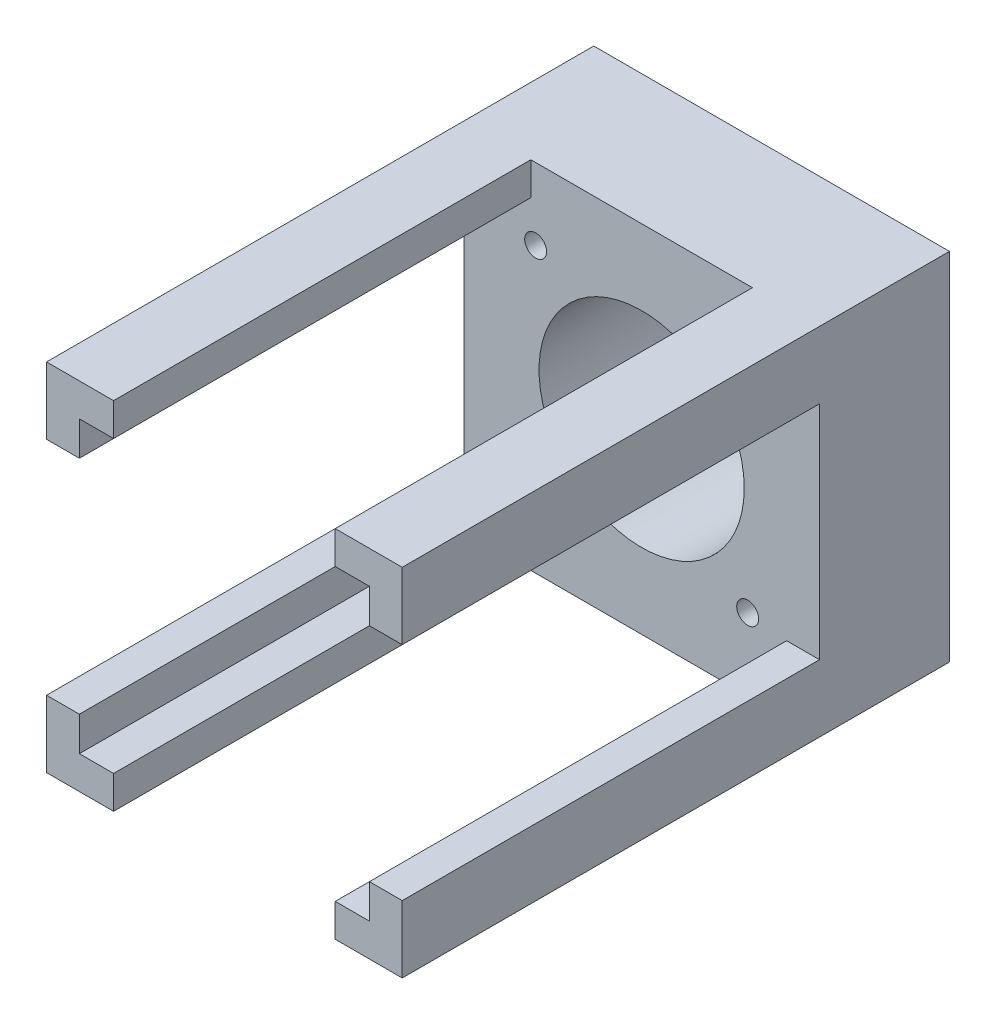
from build123d import *

# Parameters (mm, degrees)
SKETCH_1_W          = 52
SKETCH_1_H          = 52
SKETCH_1_R          = 15
SKETCH_1_R_2        = 1.6
EXTRUDE_1_DEPTH     = 80
SKETCH_2_R          = 1.6
SKETCH_2_R_2        = 15
CUT_EXTRUDE_1_DEPTH = 61


with BuildPart() as part:
    # 草图1 → 凸台-拉伸1 (new body)
    with BuildSketch(Plane.XY):
        with Locations((19.85443038, -6.661392405)):
            Rectangle(SKETCH_1_W, SKETCH_1_H)
        with Locations((19.85443038, -6.661392405)):
            Circle(SKETCH_1_R, mode=Mode.SUBTRACT)
        with Locations((35.35443038, 8.838607595)):
            Circle(SKETCH_1_R_2, mode=Mode.SUBTRACT)
        with Locations((35.35443038, -22.161392405)):
            Circle(SKETCH_1_R_2, mode=Mode.SUBTRACT)
        with Locations((4.35443038, -22.161392405)):
            Circle(SKETCH_1_R_2, mode=Mode.SUBTRACT)
        with Locations((4.35443038, 8.838607595)):
            Circle(SKETCH_1_R_2, mode=Mode.SUBTRACT)
    extrude(amount=EXTRUDE_1_DEPTH)

    # 草图2 → 切除-拉伸1 (cut)
    with BuildSketch(Plane.XY.offset(80)):
        Polygon((3.65443038, 14.538607595), (-1.34556962, 14.538607595), (-1.34556962, 9.538607595), (-6.14556962, 9.538607595), (-6.14556962, -22.861392405), (-1.34556962, -22.861392405), (-1.34556962, -27.861392405), (3.65443038, -27.861392405), (3.65443038, -32.661392405), (36.05443038, -32.661392405), (36.05443038, -27.861392405), (41.05443038, -27.861392405), (41.05443038, -22.861392405), (45.85443038, -22.861392405), (45.85443038, 9.538607595), (41.05443038, 9.538607595), (41.05443038, 14.538607595), (36.05443038, 14.538607595), (36.05443038, 19.338607595), (3.65443038, 19.338607595), align=None)
        with Locations((4.35443038, -22.161392405)):
            Circle(SKETCH_2_R, mode=Mode.SUBTRACT)
        with Locations((35.35443038, -22.161392405)):
            Circle(SKETCH_2_R, mode=Mode.SUBTRACT)
        with Locations((4.35443038, 8.838607595)):
            Circle(SKETCH_2_R, mode=Mode.SUBTRACT)
        with Locations((19.85443038, -6.661392405)):
            Circle(SKETCH_2_R_2, mode=Mode.SUBTRACT)
        with Locations((35.35443038, 8.838607595)):
            Circle(SKETCH_2_R, mode=Mode.SUBTRACT)
    extrude(amount=-CUT_EXTRUDE_1_DEPTH, mode=Mode.SUBTRACT)


solid = part.part
